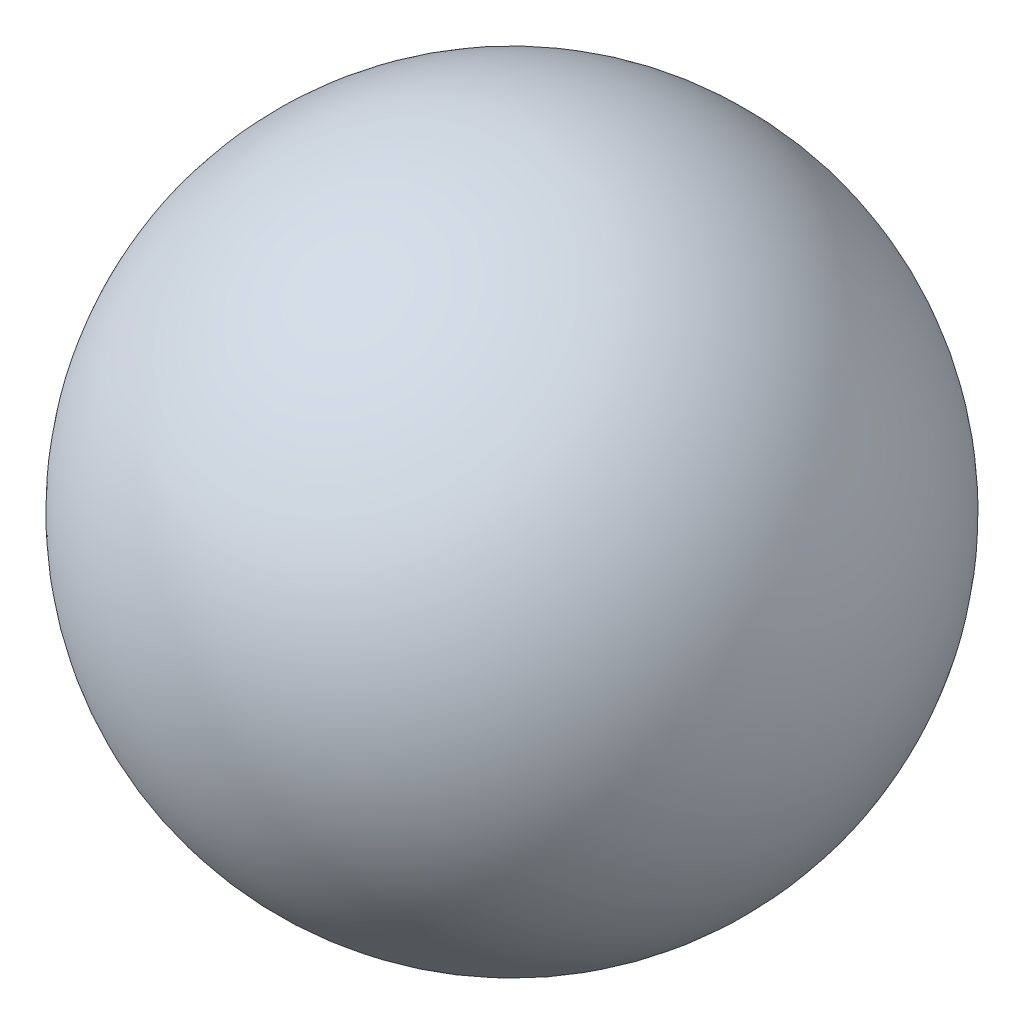
from build123d import *


with BuildPart() as part:
    # Sketch1 → Revolve1 (revolve)
    with BuildSketch(Plane.XY):
        with BuildLine():
            Line((-34, 0), (-32.5, 0))
            ThreePointArc((-32.5, 0), (0, 32.5), (32.5, 0))
            Line((32.5, 0), (34, 0))
            ThreePointArc((34, 0), (0, 34), (-34, 0))
        make_face()
    revolve(axis=Axis((-32.5, 0, 0), (1, 0, 0)))


solid = part.part
